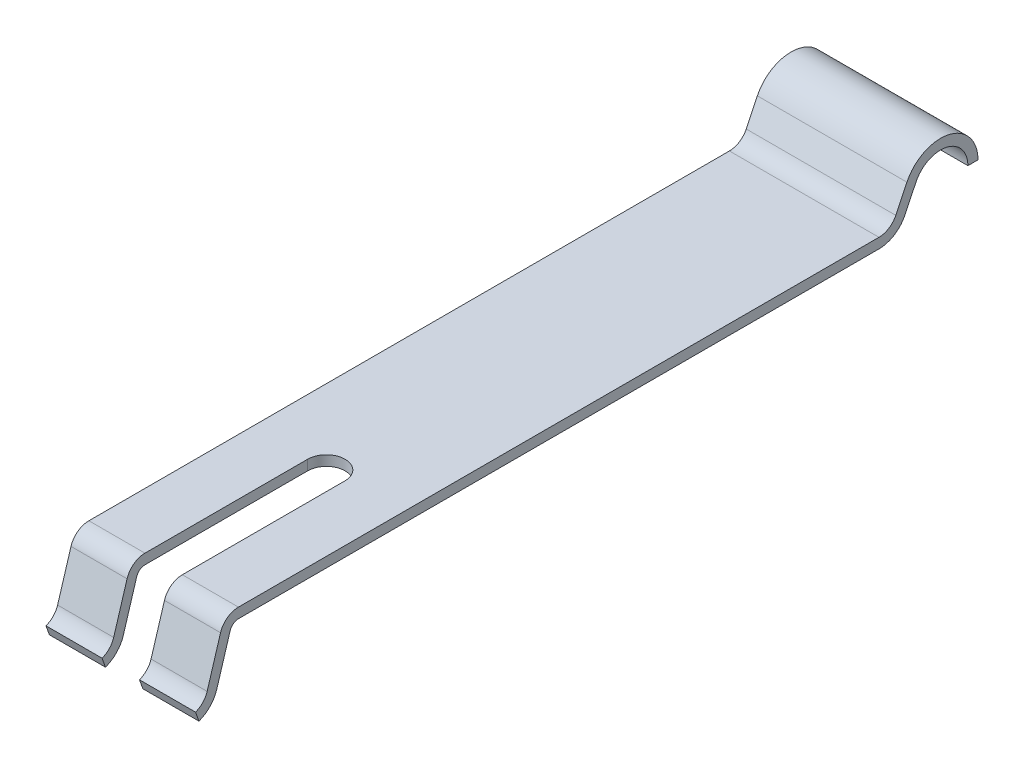
from build123d import *

# Parameters (mm, degrees)
BOSS_EXTRUDE1_DEPTH = 4
CUT_EXTRUDE1_DEPTH  = 4.15


with BuildPart() as part:
    # Sketch1 → Boss-Extrude1 (new body)
    with BuildSketch(Plane(origin=(0, 0, 0), x_dir=(0, 0, -1), z_dir=(1, 0, 0))):
        with BuildLine():
            Line((-9.035192226, 0), (8.097860886, 0))
            ThreePointArc((8.097860886, 0), (8.363999261, 0.076714795), (8.548470634, 0.283318539))
            Line((8.548470634, 0.283318539), (8.84623237, 0.902542447))
            ThreePointArc((8.84623237, 0.902542447), (9.969691043, 1.444171704), (10.747451865, 0.469179525))
            Line((10.747451865, 0.469179525), (10.477451865, 0.469179525))
            ThreePointArc((10.477451865, 0.469179525), (9.909686465, 1.180923816), (9.089561634, 0.785534458))
            Line((9.089561634, 0.785534458), (8.791799897, 0.166310551))
            ThreePointArc((8.791799897, 0.166310551), (8.507713984, -0.151859216), (8.097860886, -0.27))
            Line((8.097860886, -0.27), (-9.035192226, -0.27))
            ThreePointArc((-9.035192226, -0.27), (-9.172148547, -0.315221846), (-9.255249062, -0.433104643))
            Line((-9.255249062, -0.433104643), (-9.613802226, -1.612589711))
            ThreePointArc((-9.613802226, -1.612589711), (-9.79321671, -1.919973115), (-10.091698781, -2.113835356))
            Line((-10.091698781, -2.113835356), (-10.182452255, -1.859544564))
            ThreePointArc((-10.182452255, -1.859544564), (-9.988632728, -1.733659992), (-9.872129816, -1.534060379))
            Line((-9.872129816, -1.534060379), (-9.513576653, -0.354575311))
            ThreePointArc((-9.513576653, -0.354575311), (-9.332923359, -0.098308362), (-9.035192226, 0))
        make_face()
    extrude(amount=BOSS_EXTRUDE1_DEPTH)

    # Sketch2 → Cut-Extrude1 (cut)
    with BuildSketch(Plane(origin=(0, 0, 0), x_dir=(1, 0, 0), z_dir=(0, 1, 0))):
        with BuildLine():
            Line((1.5, -4.682452255), (1.5, -10.182452255))
            Line((1.5, -10.182452255), (2.5, -10.182452255))
            Line((2.5, -10.182452255), (2.5, -4.682452255))
            ThreePointArc((2.5, -4.682452255), (2, -4.182452255), (1.5, -4.682452255))
        make_face()
    extrude(amount=-CUT_EXTRUDE1_DEPTH, mode=Mode.SUBTRACT)


solid = part.part
